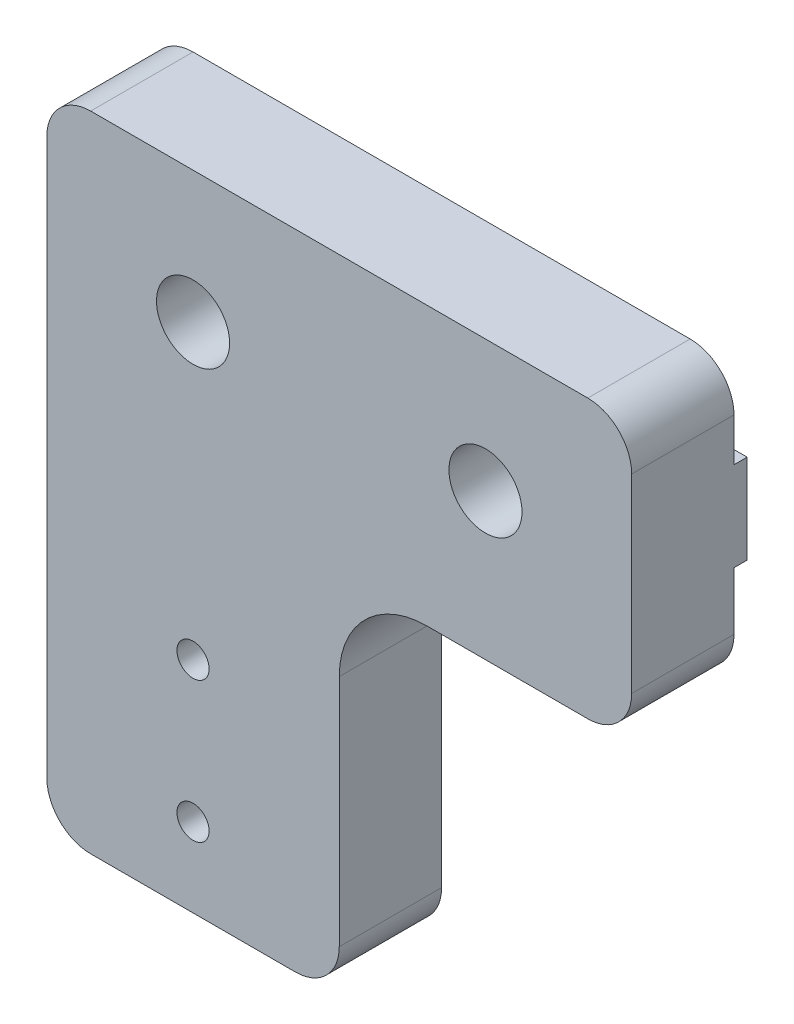
from build123d import *

# Parameters (mm, degrees)
SKETCH1_R           = 2.5
SKETCH1_R_2         = 1.1
BOSS_EXTRUDE1_DEPTH = 7
SKETCH2_W           = 0.9
SKETCH2_H           = 6.1
BOSS_EXTRUDE2_DEPTH = 40
CUT_EXTRUDE1_REACH  = 2.9
SKETCH3_R           = 2.5


with BuildPart() as part:
    # Sketch1 → Boss-Extrude1 (new body)
    with BuildSketch(Plane.XY):
        with BuildLine():
            Line((3, 0), (17, 0))
            ThreePointArc((17, 0), (19.121320344, 0.878679656), (20, 3))
            Line((20, 3), (20, 19))
            ThreePointArc((20, 19), (21.757359313, 23.242640687), (26, 25))
            Line((26, 25), (37, 25))
            ThreePointArc((37, 25), (39.121320344, 25.878679656), (40, 28))
            Line((40, 28), (40, 41))
            ThreePointArc((40, 41), (39.121320344, 43.121320344), (37, 44))
            Line((37, 44), (3, 44))
            ThreePointArc((3, 44), (0.878679656, 43.121320344), (0, 41))
            Line((0, 41), (0, 3))
            ThreePointArc((0, 3), (0.878679656, 0.878679656), (3, 0))
        make_face()
        with Locations((10, 35)):
            Circle(SKETCH1_R, mode=Mode.SUBTRACT)
        with Locations((30, 35)):
            Circle(SKETCH1_R, mode=Mode.SUBTRACT)
        with Locations((10, 5.4)):
            Circle(SKETCH1_R_2, mode=Mode.SUBTRACT)
        with Locations((10, 15)):
            Circle(SKETCH1_R_2, mode=Mode.SUBTRACT)
    extrude(amount=BOSS_EXTRUDE1_DEPTH)

    # Sketch2 → Boss-Extrude2 (add)
    with BuildSketch(Plane(origin=(40, 0, 0), x_dir=(0, 0, -1), z_dir=(1, 0, 0))):
        with Locations((0.45, 35)):
            Rectangle(SKETCH2_W, SKETCH2_H)
    extrude(amount=-BOSS_EXTRUDE2_DEPTH)

    # Sketch3 → Cut-Extrude1 (cut, up to next)
    with BuildSketch(Plane.XY, mode=Mode.PRIVATE) as cut_extrude1_sk1:
        with Locations((10, 35)):
            Circle(SKETCH3_R)
    cut_extrude1_tool1 = extrude(cut_extrude1_sk1.sketch, amount=-CUT_EXTRUDE1_REACH, mode=Mode.PRIVATE) & part.part
    add(cut_extrude1_tool1.solids().sort_by_distance((10, 35, 0))[0], mode=Mode.SUBTRACT)
    # Sketch3 → Cut-Extrude1 (cut, up to next)
    with BuildSketch(Plane.XY, mode=Mode.PRIVATE) as cut_extrude1_sk2:
        with Locations((30, 35)):
            Circle(SKETCH3_R)
    cut_extrude1_tool2 = extrude(cut_extrude1_sk2.sketch, amount=-CUT_EXTRUDE1_REACH, mode=Mode.PRIVATE) & part.part
    add(cut_extrude1_tool2.solids().sort_by_distance((30, 35, 0))[0], mode=Mode.SUBTRACT)


solid = part.part
